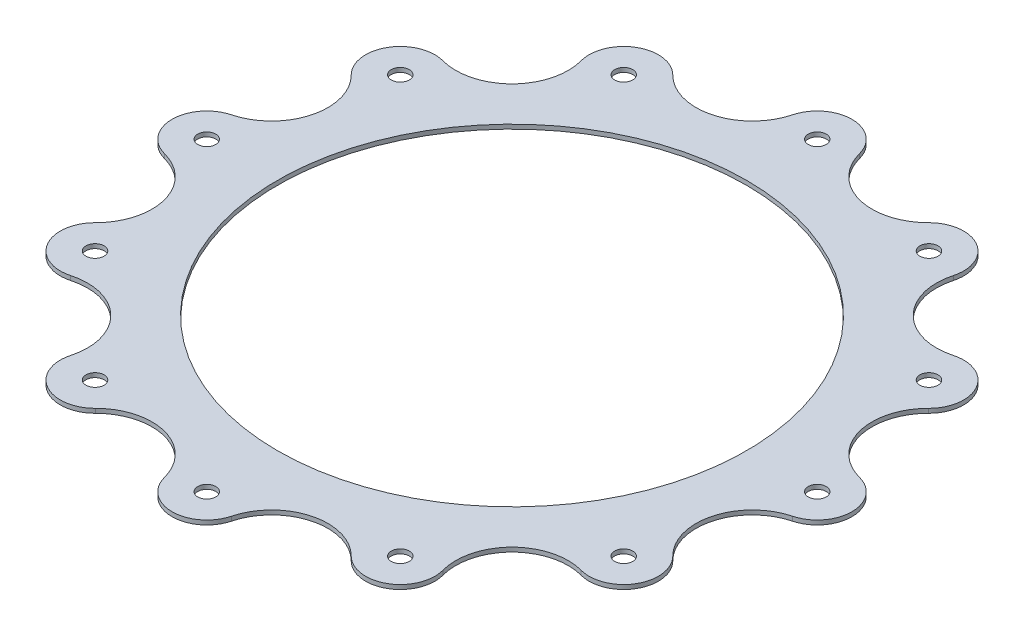
from build123d import *

# Parameters (mm, degrees)
SKETCH1_R           = 124.46
SKETCH1_R_2         = 85.8139
BOSS_EXTRUDE1_DEPTH = 1.5875
CUT_EXTRUDE1_REACH  = 178.02
SKETCH2_R           = 3.302
CIRPATTERN1_COUNT   = 12
CUT_EXTRUDE2_REACH  = 178.02
CIRPATTERN2_COUNT   = 12


with BuildPart() as part:
    # Sketch1 → Boss-Extrude1 (new body)
    with BuildSketch(Plane(origin=(0, 0, 0), x_dir=(1, 0, 0), z_dir=(0, 1, 0))):
        Circle(SKETCH1_R)
        Circle(SKETCH1_R_2, mode=Mode.SUBTRACT)
    extrude(amount=BOSS_EXTRUDE1_DEPTH)

    # Sketch2 → Cut-Extrude1 (cut, up to next)
    with BuildSketch(Plane(origin=(0, 1.5875, 0), x_dir=(1, 0, 0), z_dir=(0, 1, 0)), mode=Mode.PRIVATE) as cut_extrude1_sk1:
        with Locations((0, 111.76)):
            Circle(SKETCH2_R)
    cut_extrude1_tool1 = extrude(cut_extrude1_sk1.sketch, amount=-CUT_EXTRUDE1_REACH, mode=Mode.PRIVATE) & part.part
    cut_extrude1 = cut_extrude1_tool1.solids().sort_by_distance((0, 1.5875, -111.76))[0]
    add(cut_extrude1, mode=Mode.SUBTRACT)

    # CirPattern1: Cut-Extrude1 ×12 about axis
    cirpattern1_axis = Axis((0, 1.5875, 0), (0, -1, 0))
    for i in range(1, CIRPATTERN1_COUNT):
        add(cut_extrude1.rotate(cirpattern1_axis, i * 360 / CIRPATTERN1_COUNT), mode=Mode.SUBTRACT)

    # Sketch4 → Cut-Extrude2 (cut, up to next)
    with BuildSketch(Plane(origin=(0, 1.5875, 0), x_dir=(1, 0, 0), z_dir=(0, 1, 0)), mode=Mode.PRIVATE) as cut_extrude2_sk1:
        with BuildLine():
            Line((0, 124.46), (0, 155.146488396))
            Line((0, 155.146488396), (77.573244198, 134.360800259))
            Line((77.573244198, 134.360800259), (62.23, 107.785521755))
            ThreePointArc((62.23, 107.785521755), (54.190877213, 109.374169747), (46.855001911, 105.722289245))
            ThreePointArc((46.855001911, 105.722289245), (26.879703963, 100.316420883), (12.283522673, 114.985689189))
            ThreePointArc((12.283522673, 114.985689189), (7.756408554, 121.816248125), (0, 124.46))
        make_face()
    cut_extrude2_tool1 = extrude(cut_extrude2_sk1.sketch, amount=-CUT_EXTRUDE2_REACH, mode=Mode.PRIVATE) & part.part
    cut_extrude2 = cut_extrude2_tool1.solids().sort_by_distance((33.999093, 1.5875, -126.886343))[0]
    add(cut_extrude2, mode=Mode.SUBTRACT)

    # CirPattern2: Cut-Extrude2 ×12 about axis
    cirpattern2_axis = Axis((0, 1.5875, 0), (0, -1, 0))
    for i in range(1, CIRPATTERN2_COUNT):
        add(cut_extrude2.rotate(cirpattern2_axis, i * 360 / CIRPATTERN2_COUNT), mode=Mode.SUBTRACT)


solid = part.part
